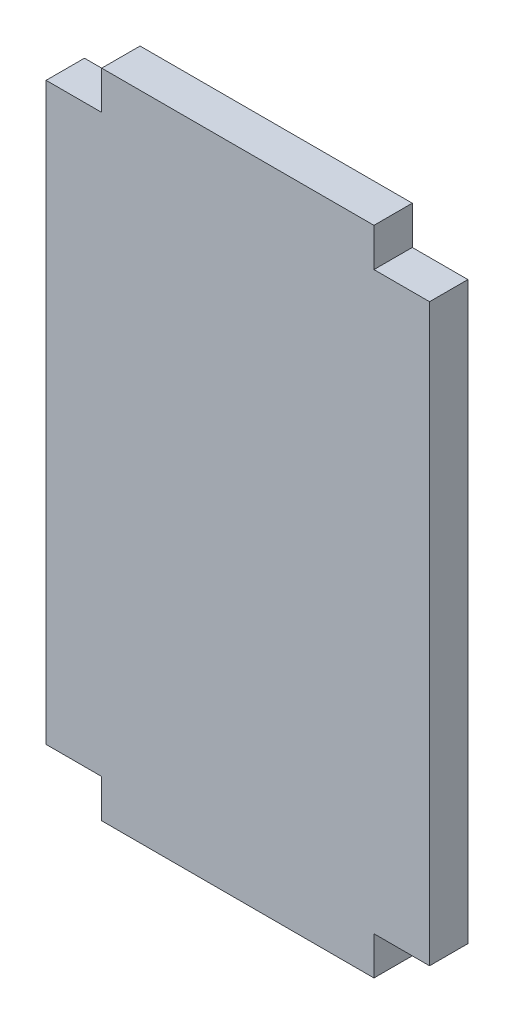
from build123d import *

# Parameters (mm, degrees)
SKETCH1_W           = 50.8
SKETCH1_H           = 86.36
BOSS_EXTRUDE1_DEPTH = 5.08
SKETCH2_W           = 7.366
SKETCH2_H           = 5.08
CUT_EXTRUDE1_DEPTH  = 5.08
SKETCH6_W           = 7.365
SKETCH6_H           = 5.08
CUT_EXTRUDE2_DEPTH  = 5.08


with BuildPart() as part:
    # Sketch1 → Boss-Extrude1 (new body)
    with BuildSketch(Plane.XY):
        with Locations((-25.4, 43.18)):
            Rectangle(SKETCH1_W, SKETCH1_H)
    extrude(amount=BOSS_EXTRUDE1_DEPTH)

    # Sketch2 → Cut-Extrude1 (cut)
    with BuildSketch(Plane(origin=(0, 86.36, 0), x_dir=(1, 0, 0), z_dir=(0, 1, 0))):
        with Locations((-47.117, -2.54)):
            Rectangle(SKETCH2_W, SKETCH2_H)
        with Locations((-3.683, -2.54)):
            Rectangle(SKETCH2_W, SKETCH2_H)
    extrude(amount=-CUT_EXTRUDE1_DEPTH, mode=Mode.SUBTRACT)

    # Sketch6 → Cut-Extrude2 (cut)
    with BuildSketch(Plane(origin=(0, 0, 0), x_dir=(-1, 0, 0), z_dir=(0, -1, 0))):
        with Locations((47.1175, -2.54)):
            Rectangle(SKETCH6_W, SKETCH6_H)
        with Locations((3.6825, -2.54)):
            Rectangle(SKETCH6_W, SKETCH6_H)
    extrude(amount=-CUT_EXTRUDE2_DEPTH, mode=Mode.SUBTRACT)


solid = part.part
